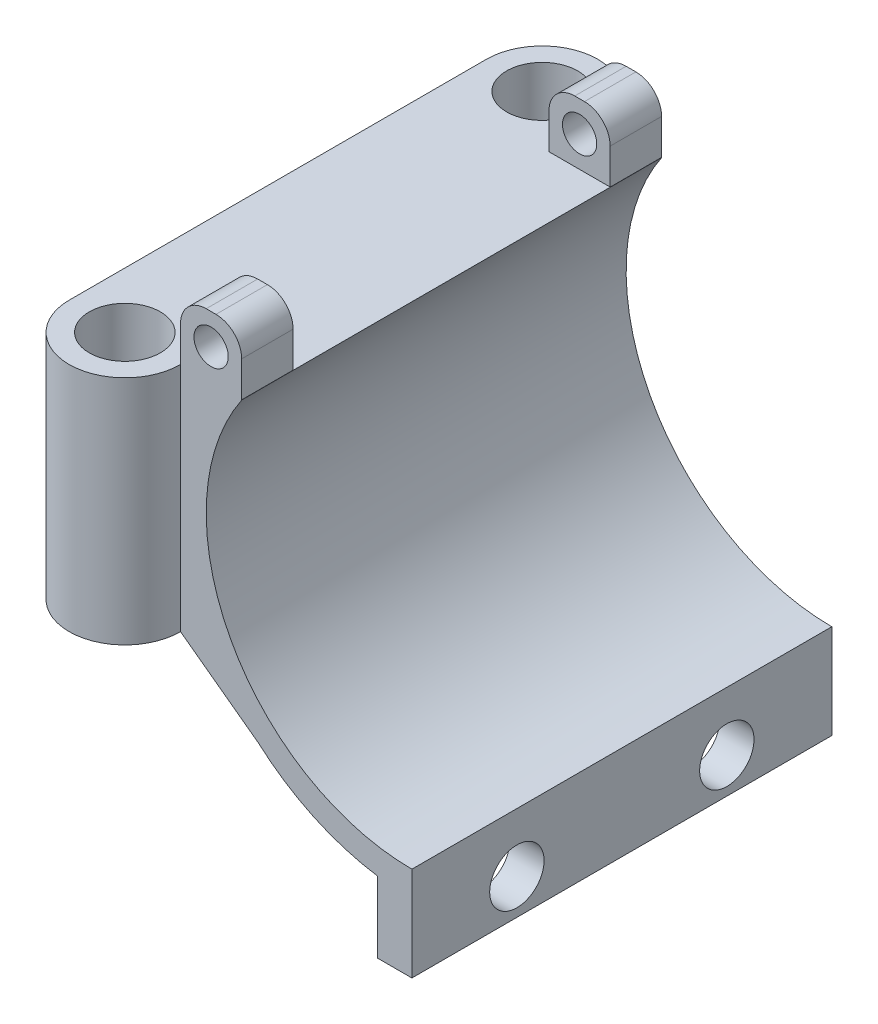
from build123d import *

# Parameters (mm, degrees)
SKETCH1_R           = 4.15
BOSS_EXTRUDE1_DEPTH = 27
BOSS_EXTRUDE2_DEPTH = 49
SKETCH3_W           = 7.137224295
SKETCH3_H           = 7.139279227
BOSS_EXTRUDE3_DEPTH = 49
SKETCH4_R           = 2
CUT_EXTRUDE1_DEPTH  = 51
FILLET1_R           = 3
SKETCH5_W           = 7.156865167
SKETCH5_H           = 37
CUT_EXTRUDE2_DEPTH  = 7.139279
SKETCH7_W           = 36.574972609
SKETCH7_H           = 48.532858444
CUT_EXTRUDE3_DEPTH  = 51
SKETCH8_W           = 4
SKETCH8_H           = 11
BOSS_EXTRUDE4_DEPTH = 49
SKETCH10_R          = 3.175
CUT_EXTRUDE4_DEPTH  = 49


with BuildPart() as part:
    # Sketch1 → Boss-Extrude1 (new body)
    with BuildSketch(Plane(origin=(0, 0, 0), x_dir=(1, 0, 0), z_dir=(0, 1, 0))):
        with BuildLine():
            Line((-6.5, 48.7), (-6.5, 0))
            ThreePointArc((-6.5, 0), (0, -6.5), (6.5, 0))
            Line((6.5, 0), (6.5, 48.7))
            ThreePointArc((6.5, 48.7), (0, 55.2), (-6.5, 48.7))
        make_face()
        with Locations(Location((0, 0, 0), (0, 0, 270))):  # turned: the seam where the file's is
            Circle(SKETCH1_R, mode=Mode.SUBTRACT)
        with Locations(Location((0, 48.7, 0), (0, 0, 270))):  # turned: the seam where the file's is
            Circle(SKETCH1_R, mode=Mode.SUBTRACT)
    extrude(amount=BOSS_EXTRUDE1_DEPTH)

    # Sketch2 → Boss-Extrude2 (add)
    with BuildSketch(Plane.XY):
        with BuildLine():
            Line((6.5, 27), (6.5, 0))
            Line((6.5, 0), (15.568570347, -6.685733343))
            ThreePointArc((15.568570347, -6.685733343), (43.70403904, -11.497551626), (60.435084664, 11.628846841))
            Line((60.435084664, 11.628846841), (62.638339389, 10.782838022))
            Line((62.638339389, 10.782838022), (62.638339389, 13.5))
            Line((62.638339389, 13.5), (57.5, 13.5))
            ThreePointArc((57.5, 13.5), (26.437253933, -9.437253933), (13.656865167, 27))
            Line((13.656865167, 27), (6.5, 27))
        make_face()
    extrude(amount=-BOSS_EXTRUDE2_DEPTH)

    # Sketch3 → Boss-Extrude3 (add)
    with BuildSketch(Plane.XY):
        with Locations((10.068612148, 30.569639614)):
            Rectangle(SKETCH3_W, SKETCH3_H)
    extrude(amount=-BOSS_EXTRUDE3_DEPTH)

    # Sketch4 → Cut-Extrude1 (cut)
    with BuildSketch(Plane.XY):
        with Locations((10.068612147, 30.569639613)):
            Circle(SKETCH4_R)
    extrude(amount=-CUT_EXTRUDE1_DEPTH, mode=Mode.SUBTRACT)

    # Fillet1
    fillet1_edges = [part.edges().sort_by_distance(p)[0] for p in [
        (6.5, 34.139279227, -24.5),
        (13.637224295, 34.139279227, -24.5),
    ]]
    fillet(fillet1_edges, radius=FILLET1_R)

    # Sketch5 → Cut-Extrude2 (cut)
    with BuildSketch(Plane(origin=(0, 34.139279227, 0), x_dir=(1, 0, 0), z_dir=(0, 1, 0))):
        with Locations((10.078432583, 24.5)):
            Rectangle(SKETCH5_W, SKETCH5_H)
    extrude(amount=-CUT_EXTRUDE2_DEPTH, mode=Mode.SUBTRACT)

    # Sketch7 → Cut-Extrude3 (cut)
    with BuildSketch(Plane.XY):
        with Locations((51.787486304, 3.889520552)):
            Rectangle(SKETCH7_W, SKETCH7_H)
    extrude(amount=-CUT_EXTRUDE3_DEPTH, mode=Mode.SUBTRACT)

    # Sketch8 → Boss-Extrude4 (add)
    with BuildSketch(Plane.XY):
        with Locations((31.5, -16)):
            Rectangle(SKETCH8_W, SKETCH8_H)
    extrude(amount=-BOSS_EXTRUDE4_DEPTH)

    # Sketch10 → Cut-Extrude4 (cut)
    with BuildSketch(Plane.ZY.offset(-29.5)):
        with Locations(Location((-36.75, -17.351029923, 0), (0, 0, 270))):  # turned: the seam where the file's is
            Circle(SKETCH10_R)
        with Locations(Location((-12.25, -17.351029923, 0), (0, 0, 270))):  # turned: the seam where the file's is
            Circle(SKETCH10_R)
    extrude(amount=-CUT_EXTRUDE4_DEPTH, mode=Mode.SUBTRACT)


solid = part.part
